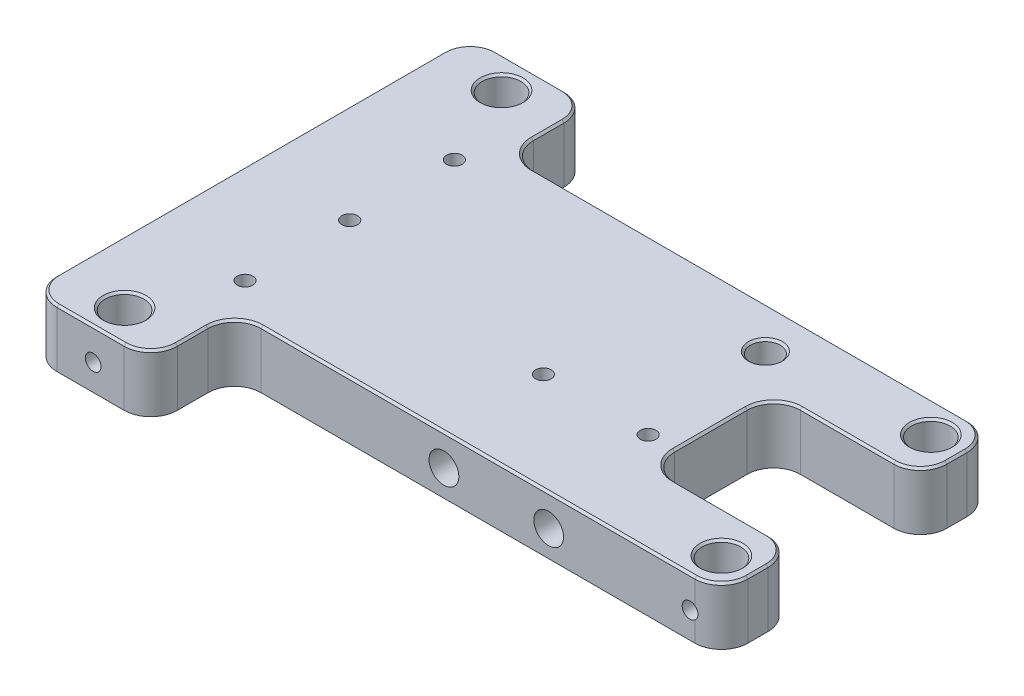
from build123d import *

# Parameters (mm, degrees)
SKETCH1_W                                 = 58
SKETCH1_H                                 = 42
EXTRUDE1_DEPTH                            = 5.5
SKETCH2_W                                 = 14
SKETCH2_H                                 = 12
EXTRUDE2_DEPTH                            = 6.5
SKETCH3_W                                 = 46.5
SKETCH3_H                                 = 8
EXTRUDE3_DEPTH                            = 6.5
SKETCH4_R                                 = 1.85
EXTRUDE4_DEPTH                            = 6.5
FILLET2_R                                 = 2.54
F_4_40_TAPPED_HOLE1_D                     = 2.2606
F_4_40_TAPPED_HOLE1_DEPTH                 = 10.135
F_4_40_TAPPED_HOLE1_CBORE_D               = 2.8448
F_4_40_TAPPED_HOLE1_CBORE_DEPTH           = 8.23
F_4_40_TAPPED_HOLE1_TIP                   = 0.679152758
CHAMFER1_SIZE                             = 0.2
SKETCH6_W                                 = 36.92
SKETCH6_H                                 = 0.5
EXTRUDE5_DEPTH                            = 1
F_4_40_TAPPED_HOLE2_D                     = 2.2606
F_4_40_TAPPED_HOLE2_DEPTH                 = 9.525
F_4_40_TAPPED_HOLE2_CBORE_D               = 2.8448
F_4_40_TAPPED_HOLE2_CBORE_DEPTH           = 8.2296
F_4_40_TAPPED_HOLE2_TIP                   = 0.679152758
F_4_40_TAPPED_HOLE2_ON_FACE_2_D           = 2.2606
F_4_40_TAPPED_HOLE2_ON_FACE_2_DEPTH       = 9.525
F_4_40_TAPPED_HOLE2_ON_FACE_2_CBORE_D     = 2.8448
F_4_40_TAPPED_HOLE2_ON_FACE_2_CBORE_DEPTH = 8.2296
F_4_40_TAPPED_HOLE2_ON_FACE_2_TIP         = 0.679152758
SKETCH8_R                                 = 0.75
EXTRUDE6_DEPTH                            = 2.5
SKETCH9_R                                 = 0.75
EXTRUDE7_DEPTH                            = 2.5
SKETCH10_R                                = 0.75
EXTRUDE8_DEPTH                            = 2.5


with BuildPart() as part:
    # Sketch1 → Extrude1 (new body)
    with BuildSketch(Plane(origin=(0, 0, 0), x_dir=(1, 0, 0), z_dir=(0, 1, 0))):
        with Locations((-29, 21)):
            Rectangle(SKETCH1_W, SKETCH1_H)
    extrude(amount=EXTRUDE1_DEPTH)

    # Sketch2 → Extrude2 (cut, through all)
    with BuildSketch(Plane(origin=(0, 5.5, 0), x_dir=(1, 0, 0), z_dir=(0, 1, 0))):
        with Locations((-7, 21)):
            Rectangle(SKETCH2_W, SKETCH2_H)
    extrude(amount=-EXTRUDE2_DEPTH, mode=Mode.SUBTRACT)

    # Sketch3 → Extrude3 (cut, through all)
    with BuildSketch(Plane(origin=(0, 5.5, 0), x_dir=(1, 0, 0), z_dir=(0, 1, 0))):
        with Locations((-23.25, 38)):
            Rectangle(SKETCH3_W, SKETCH3_H)
    extrude3 = extrude(amount=-EXTRUDE3_DEPTH, mode=Mode.SUBTRACT)

    # Sketch4 → Extrude4 (cut, through all)
    with BuildSketch(Plane(origin=(0, 5.5, 0), x_dir=(1, 0, 0), z_dir=(0, 1, 0))):
        with Locations(Location((-52, 39, 0), (0, 0, 270))):  # turned: the seam where the file's is
            Circle(SKETCH4_R)
        with Locations(Location((-3, 31, 0), (0, 0, 270))):  # turned: the seam where the file's is
            Circle(SKETCH4_R)
    extrude4 = extrude(amount=-EXTRUDE4_DEPTH, mode=Mode.SUBTRACT)

    # Mirror2: Extrude3, Extrude4 across plane
    add(extrude3.mirror(Plane(origin=(0, 0, -21), x_dir=(1, 0, 0), z_dir=(0, 0, -1))), mode=Mode.SUBTRACT)
    add(extrude4.mirror(Plane(origin=(0, 0, -21), x_dir=(1, 0, 0), z_dir=(0, 0, -1))), mode=Mode.SUBTRACT)

    # Fillet2
    fillet2_edges = [part.edges().sort_by_distance(p)[0] for p in [
        (0, 2.75, -27),
        (0, 2.75, -15),
        (-14, 2.75, -15),
        (-14, 2.75, -27),
        (0, 2.75, -34),
        (-46.5, 2.75, -34),
        (-46.5, 2.75, -42),
        (0, 2.75, -8),
        (-46.5, 2.75, 0),
        (-46.5, 2.75, -8),
        (-58, 2.75, -42),
        (-58, 2.75, 0),
    ]]
    fillet(fillet2_edges, radius=FILLET2_R)

    # #4-40 Tapped Hole1
    with Locations(Plane(origin=(-17.8, 5.5, -30), x_dir=(0, 0, 1), z_dir=(0, 1, 0))):
        with Locations((0, 0)):
            CounterBoreHole(F_4_40_TAPPED_HOLE1_D / 2, F_4_40_TAPPED_HOLE1_CBORE_D / 2, F_4_40_TAPPED_HOLE1_CBORE_DEPTH, depth=F_4_40_TAPPED_HOLE1_DEPTH)
            with Locations((0, 0, -(F_4_40_TAPPED_HOLE1_DEPTH + F_4_40_TAPPED_HOLE1_TIP / 2))):  # 118° drill point
                Cone(0, F_4_40_TAPPED_HOLE1_D / 2, F_4_40_TAPPED_HOLE1_TIP, mode=Mode.SUBTRACT)

    # Chamfer1
    chamfer1_edges = [part.edges().sort_by_distance(p)[0] for p in [
        (-47.243948776, 5.5, -0.743948776),
        (-0.743948776, 5.5, -8.743948776),
        (-0.743948776, 5.5, -14.256051224),
        (-0.743948776, 5.5, -27.743948776),
        (-0.743948776, 5.5, -33.256051224),
        (-47.243948776, 5.5, -41.256051224),
        (-57.256051224, 5.5, -41.256051224),
        (-45.756051224, 5.5, -34.743948776),
        (-13.256051224, 5.5, -15.743948776),
        (-13.256051224, 5.5, -26.256051224),
        (-45.756051224, 5.5, -7.256051224),
        (-17.8, 5.5, -31.4224),
        (-52, 5.5, -40.85),
        (-3, 5.5, -32.85),
        (-52, 5.5, -1.15),
        (-3, 5.5, -9.15),
        (-58, 5.5, -21),
        (-52.25, 5.5, -42),
        (-52.25, 5.5, 0),
        (-46.5, 5.5, -4),
        (-23.25, 5.5, -8),
        (0, 5.5, -11.5),
        (-7, 5.5, -15),
        (-14, 5.5, -21),
        (-7, 5.5, -27),
        (0, 5.5, -30.5),
        (-23.25, 5.5, -34),
        (-46.5, 5.5, -38),
        (-57.256051224, 5.5, -0.743948776),
    ]]
    chamfer(chamfer1_edges, length=CHAMFER1_SIZE)

    # Sketch6 → Extrude5 (add)
    with BuildSketch(Plane.ZY.offset(58)):
        with Locations((-21, 0.25)):
            Rectangle(SKETCH6_W, SKETCH6_H)
    extrude(amount=EXTRUDE5_DEPTH)

    # #4-40 Tapped Hole2
    with Locations(Plane(origin=(-16.5, 2.5, -8), x_dir=(1, 0, 0), z_dir=(0, 0, 1))):
        with Locations((0, 0), (-10, 0)):
            CounterBoreHole(F_4_40_TAPPED_HOLE2_D / 2, F_4_40_TAPPED_HOLE2_CBORE_D / 2, F_4_40_TAPPED_HOLE2_CBORE_DEPTH, depth=F_4_40_TAPPED_HOLE2_DEPTH)
            with Locations((0, 0, -(F_4_40_TAPPED_HOLE2_DEPTH + F_4_40_TAPPED_HOLE2_TIP / 2))):  # 118° drill point
                Cone(0, F_4_40_TAPPED_HOLE2_D / 2, F_4_40_TAPPED_HOLE2_TIP, mode=Mode.SUBTRACT)

    # #4-40 Tapped Hole2 on face 2
    with Locations(Plane(origin=(-58, 3, -11), x_dir=(0, 0, -1), z_dir=(-1, 0, 0))):
        with Locations((0, 0), (10, 0), (20, 0)):
            CounterBoreHole(F_4_40_TAPPED_HOLE2_ON_FACE_2_D / 2, F_4_40_TAPPED_HOLE2_ON_FACE_2_CBORE_D / 2, F_4_40_TAPPED_HOLE2_ON_FACE_2_CBORE_DEPTH, depth=F_4_40_TAPPED_HOLE2_ON_FACE_2_DEPTH)
            with Locations((0, 0, -(F_4_40_TAPPED_HOLE2_ON_FACE_2_DEPTH + F_4_40_TAPPED_HOLE2_ON_FACE_2_TIP / 2))):  # 118° drill point
                Cone(0, F_4_40_TAPPED_HOLE2_ON_FACE_2_D / 2, F_4_40_TAPPED_HOLE2_ON_FACE_2_TIP, mode=Mode.SUBTRACT)

    # Sketch8 → Extrude6 (cut)
    with BuildSketch(Plane(origin=(0, 5.5, 0), x_dir=(1, 0, 0), z_dir=(0, 1, 0))):
        with Locations(Location((-48.5, 31, 0), (0, 0, 270))):  # turned: the seam where the file's is
            Circle(SKETCH8_R)
        with Locations(Location((-48.5, 21, 0), (0, 0, 270))):  # turned: the seam where the file's is
            Circle(SKETCH8_R)
        with Locations(Location((-48.5, 11, 0), (0, 0, 270))):  # turned: the seam where the file's is
            Circle(SKETCH8_R)
        with Locations(Location((-26.5, 17.5, 0), (0, 0, 270))):  # turned: the seam where the file's is
            Circle(SKETCH8_R)
        with Locations(Location((-16.5, 17.5, 0), (0, 0, 270))):  # turned: the seam where the file's is
            Circle(SKETCH8_R)
    extrude(amount=-EXTRUDE6_DEPTH, mode=Mode.SUBTRACT)

    # Sketch9 → Extrude7 (cut)
    with BuildSketch(Plane.XY.offset(-8)):
        with Locations(Location((-3, 2.5, 0), (0, 0, 307.830916896))):  # turned: the seam where the file's is
            Circle(SKETCH9_R)
    extrude7 = extrude(amount=-EXTRUDE7_DEPTH, mode=Mode.SUBTRACT)

    # Sketch10 → Extrude8 (cut)
    with BuildSketch(Plane.XY):
        with Locations((-52, 2.5)):
            Circle(SKETCH10_R)
    extrude8 = extrude(amount=-EXTRUDE8_DEPTH, mode=Mode.SUBTRACT)

    # Mirror3: Extrude7, Extrude8 across plane
    add(extrude7.mirror(Plane(origin=(0, 0, -21), x_dir=(1, 0, 0), z_dir=(0, 0, -1))), mode=Mode.SUBTRACT)
    add(extrude8.mirror(Plane(origin=(0, 0, -21), x_dir=(1, 0, 0), z_dir=(0, 0, -1))), mode=Mode.SUBTRACT)


solid = part.part
